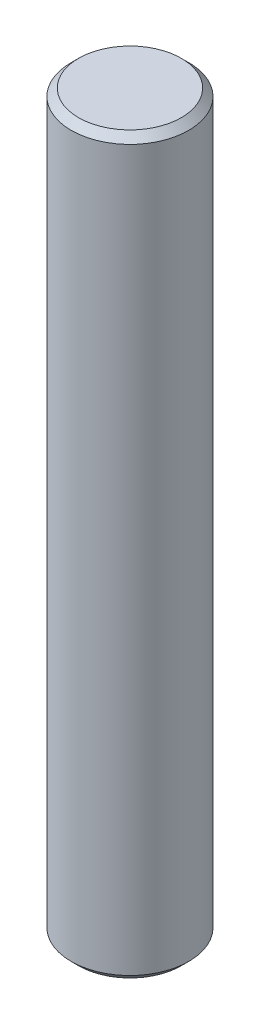
from build123d import *

# Parameters (mm, degrees)
SKETCH2_R           = 4
BOSS_EXTRUDE1_DEPTH = 50
CHAMFER1_SIZE       = 0.5


with BuildPart() as part:
    # Sketch2 → Boss-Extrude1 (new body)
    with BuildSketch(Plane(origin=(0, 0, 0), x_dir=(1, 0, 0), z_dir=(0, 1, 0))):
        Circle(SKETCH2_R)
    extrude(amount=BOSS_EXTRUDE1_DEPTH)

    # Chamfer1
    chamfer1_edges = [part.edges().sort_by_distance(p)[0] for p in [
        (-4, 0, 0),
        (-4, 50, 0),
    ]]
    chamfer(chamfer1_edges, length=CHAMFER1_SIZE)


solid = part.part
